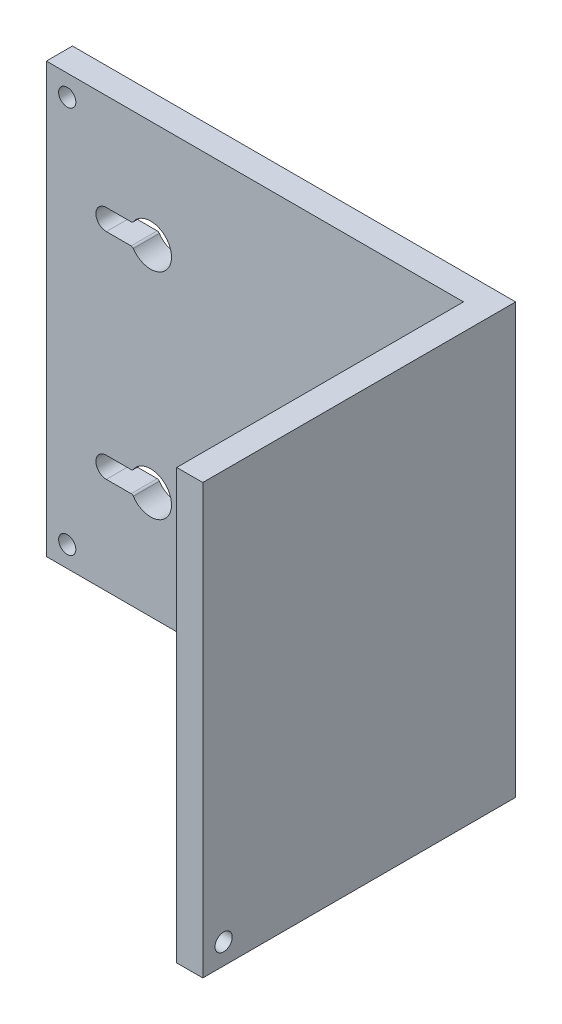
from build123d import *

# Parameters (mm, degrees)
SKETCH1_W            = 85
SKETCH1_H            = 82.3
BOSS_EXTRUDE1_DEPTH  = 60
SKETCH2_W            = 80
SKETCH2_H            = 55
CUT_EXTRUDE1_DEPTH   = 83.3
CUT_EXTRUDE2_DEPTH   = 50
FILLET1_R            = 0.5
FILLET1_OF_MIRROR1_R = 0.5
SKETCH4_R            = 1.65
CUT_EXTRUDE3_DEPTH   = 20
SKETCH5_R            = 1.65
CUT_EXTRUDE4_DEPTH   = 20


with BuildPart() as part:
    # Sketch1 → Boss-Extrude1 (new body)
    with BuildSketch(Plane.XY):
        with Locations((42.5, -41.15)):
            Rectangle(SKETCH1_W, SKETCH1_H)
    extrude(amount=BOSS_EXTRUDE1_DEPTH)

    # Sketch2 → Cut-Extrude1 (cut, through all)
    with BuildSketch(Plane.XZ.offset(82.3)):
        with Locations((40, 32.5)):
            Rectangle(SKETCH2_W, SKETCH2_H)
    extrude(amount=-CUT_EXTRUDE1_DEPTH, mode=Mode.SUBTRACT)

    # Sketch3 → Cut-Extrude2 (cut)
    with BuildSketch(Plane.XY.offset(5)):
        with BuildLine():
            Line((16.535898385, -63.725), (11.5, -63.725))
            ThreePointArc((11.5, -63.725), (9.5, -61.725), (11.5, -59.725))
            Line((11.5, -59.725), (16.535898385, -59.725))
            ThreePointArc((16.535898385, -59.725), (24, -61.725), (16.535898385, -63.725))
        make_face()
    cut_extrude2 = extrude(amount=-CUT_EXTRUDE2_DEPTH, mode=Mode.SUBTRACT)

    # Fillet1
    fillet1_edges = [part.edges().sort_by_distance(p)[0] for p in [
        (16.535898385, -59.725, 2.5),
        (16.535898385, -63.725, 2.5),
    ]]
    fillet(fillet1_edges, radius=FILLET1_R)

    # Mirror1: Cut-Extrude2 across plane
    add(cut_extrude2.mirror(Plane(origin=(0, -41.15, 0), x_dir=(0, 0, 1), z_dir=(0, -1, 0))), mode=Mode.SUBTRACT)

    # Fillet1 of Mirror1
    fillet1_of_mirror1_edges = [part.edges().sort_by_distance(p)[0] for p in [
        (16.535898385, -22.575, 2.5),
        (16.535898385, -18.575, 2.5),
    ]]
    fillet(fillet1_of_mirror1_edges, radius=FILLET1_OF_MIRROR1_R)

    # Sketch4 → Cut-Extrude3 (cut)
    with BuildSketch(Plane(origin=(85, 0, 0), x_dir=(0, 0, -1), z_dir=(1, 0, 0))):
        with Locations((-56, -78.3)):
            Circle(SKETCH4_R)
    extrude(amount=-CUT_EXTRUDE3_DEPTH, mode=Mode.SUBTRACT)

    # Sketch5 → Cut-Extrude4 (cut)
    with BuildSketch(Plane(origin=(0, 0, 0), x_dir=(-1, 0, 0), z_dir=(0, 0, -1))):
        with Locations((-4, -4)):
            Circle(SKETCH5_R)
        with Locations((-4, -78.3)):
            Circle(SKETCH5_R)
    extrude(amount=-CUT_EXTRUDE4_DEPTH, mode=Mode.SUBTRACT)


solid = part.part
